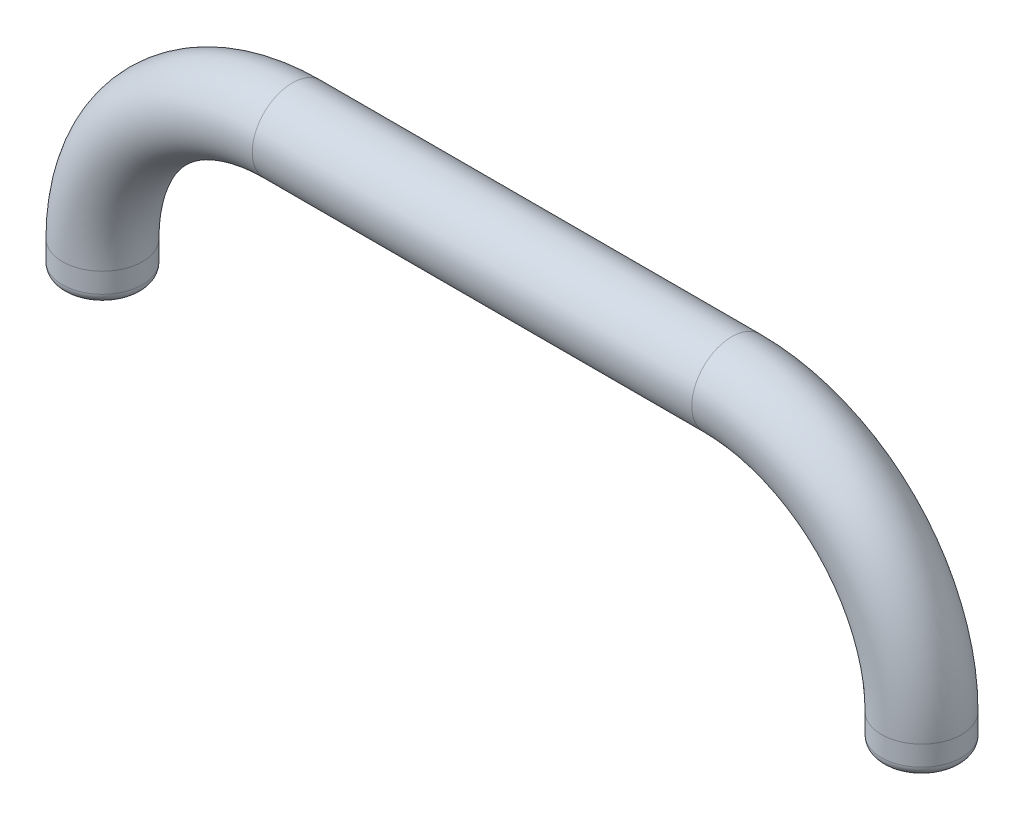
from build123d import *

# Parameters (mm, degrees)
SKETCH2_R = 4
FILLET1_R = 1


with BuildPart() as part:
    # Sweep1: sweep along a path in Sketch1
    with BuildLine(Plane.XY) as sweep1_path:
        Line((41, -22), (41, -19))
        ThreePointArc((41, -19), (35.435028843, -5.564971157), (22, 0))
        Line((22, 0), (-22, 0))
        ThreePointArc((-22, 0), (-35.435028843, -5.564971157), (-41, -19))
        Line((-41, -19), (-41, -22))
    # Sketch2 → Sweep1 (sweep)
    with BuildSketch(Plane(origin=(41, -22, 0), x_dir=(1, 0, 0), z_dir=(0, -1, 0))):
        Circle(SKETCH2_R)
    sweep(path=sweep1_path.line)

    # Fillet1
    fillet1_edges = [part.edges().sort_by_distance(p)[0] for p in [
        (37, -22, 0),
        (-37, -22, 0),
    ]]
    fillet(fillet1_edges, radius=FILLET1_R)


solid = part.part
